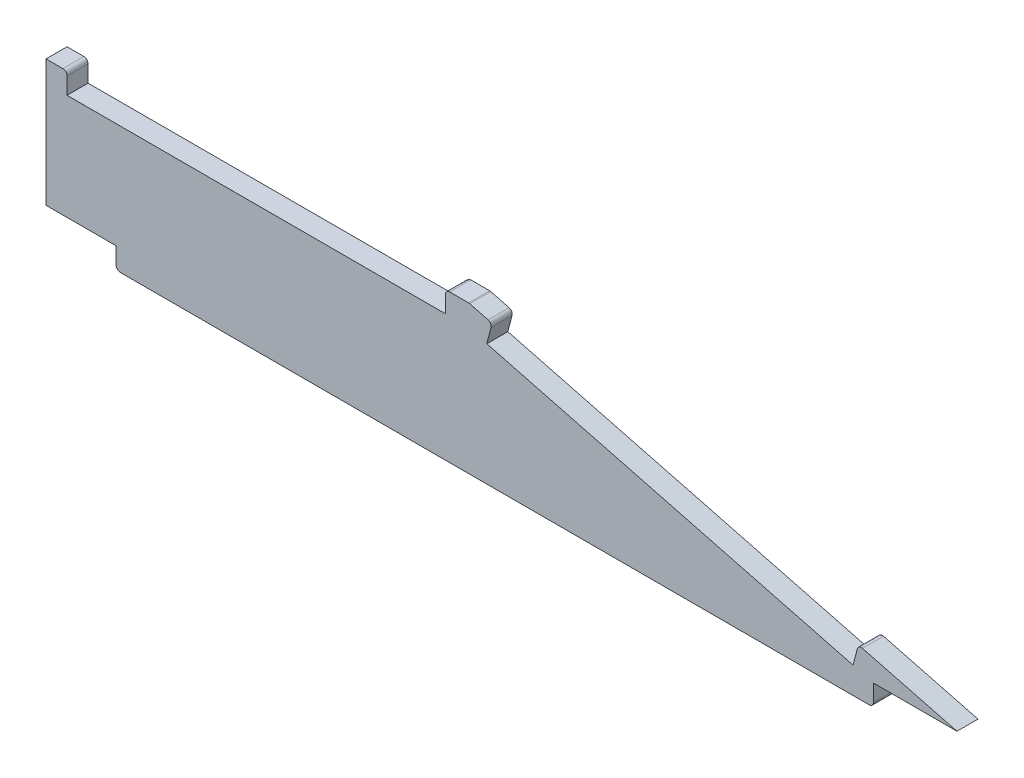
from build123d import *

# Parameters (mm, degrees)
BOSS_EXTRUDE1_DEPTH = 5
FILLET1_R           = 1


with BuildPart() as part:
    # Sketch1 → Boss-Extrude1 (new body)
    with BuildSketch(Plane.XY):
        Polygon((29.405194241, 5), (46.088102842, 5), (46.088102842, 0), (226.188102842, 0), (226.188102842, 5), (246.060241867, 5), (222.607000141, 11.097188159), (221.348957412, 6.258042728), (134.244339671, 28.902811841), (135.5023824, 33.741957272), (130.044499116, 35.16085457), (124.405194241, 35.16085457), (124.405194241, 30.16085457), (34.405194241, 30.16085457), (34.405194241, 35.16085457), (29.405194241, 35.16085457), align=None)
    extrude(amount=BOSS_EXTRUDE1_DEPTH)

    # Fillet1
    fillet1_edges = [part.edges().sort_by_distance(p)[0] for p in [
        (130.044499116, 35.16085457, 2.5),
        (135.5023824, 33.741957272, 2.5),
        (222.607000141, 11.097188159, 2.5),
        (226.188102842, 0, 2.5),
        (46.088102842, 0, 2.5),
        (34.405194241, 35.16085457, 2.5),
        (124.405194241, 35.16085457, 2.5),
    ]]
    fillet(fillet1_edges, radius=FILLET1_R)


solid = part.part
